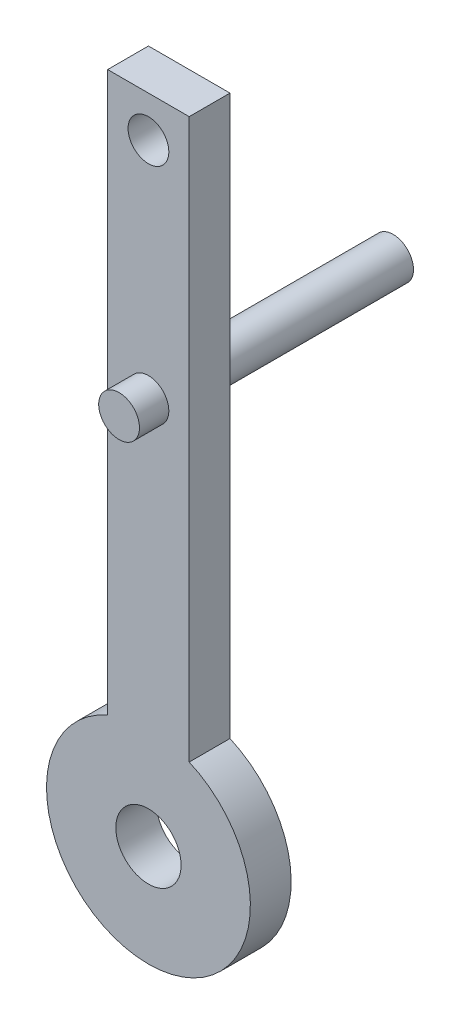
from build123d import *

# Parameters (mm, degrees)
SKETCH1_R           = 4
BOSS_EXTRUDE1_DEPTH = 5
SKETCH2_R           = 2.5
CUT_EXTRUDE1_DEPTH  = 6
SKETCH3_R           = 2.5
BOSS_EXTRUDE2_DEPTH = 3.6
SKETCH4_R           = 2.5
BOSS_EXTRUDE3_DEPTH = 25


with BuildPart() as part:
    # Sketch1 → Boss-Extrude1 (new body)
    with BuildSketch(Plane.XY):
        with BuildLine():
            Line((0, 0), (0, 68.543560763))
            Line((0, 68.543560763), (10, 68.543560763))
            Line((10, 68.543560763), (10, 0))
            ThreePointArc((10, 0), (5, -23.956439237), (0, 0))
        make_face()
        with Locations((5, -11.456439237)):
            Circle(SKETCH1_R, mode=Mode.SUBTRACT)
    extrude(amount=BOSS_EXTRUDE1_DEPTH)

    # Sketch2 → Cut-Extrude1 (cut, through all)
    with BuildSketch(Plane.XY.offset(5)):
        with Locations((5, 63.543560763)):
            Circle(SKETCH2_R)
    extrude(amount=-CUT_EXTRUDE1_DEPTH, mode=Mode.SUBTRACT)

    # Sketch3 → Boss-Extrude2 (add)
    with BuildSketch(Plane.XY.offset(5)):
        with Locations((5, 36.043560763)):
            Circle(SKETCH3_R)
    extrude(amount=BOSS_EXTRUDE2_DEPTH)

    # Sketch4 → Boss-Extrude3 (add)
    with BuildSketch(Plane(origin=(0, 0, 0), x_dir=(-1, 0, 0), z_dir=(0, 0, -1))):
        with Locations((-5, 36.043560763)):
            Circle(SKETCH4_R)
    extrude(amount=BOSS_EXTRUDE3_DEPTH)


solid = part.part
